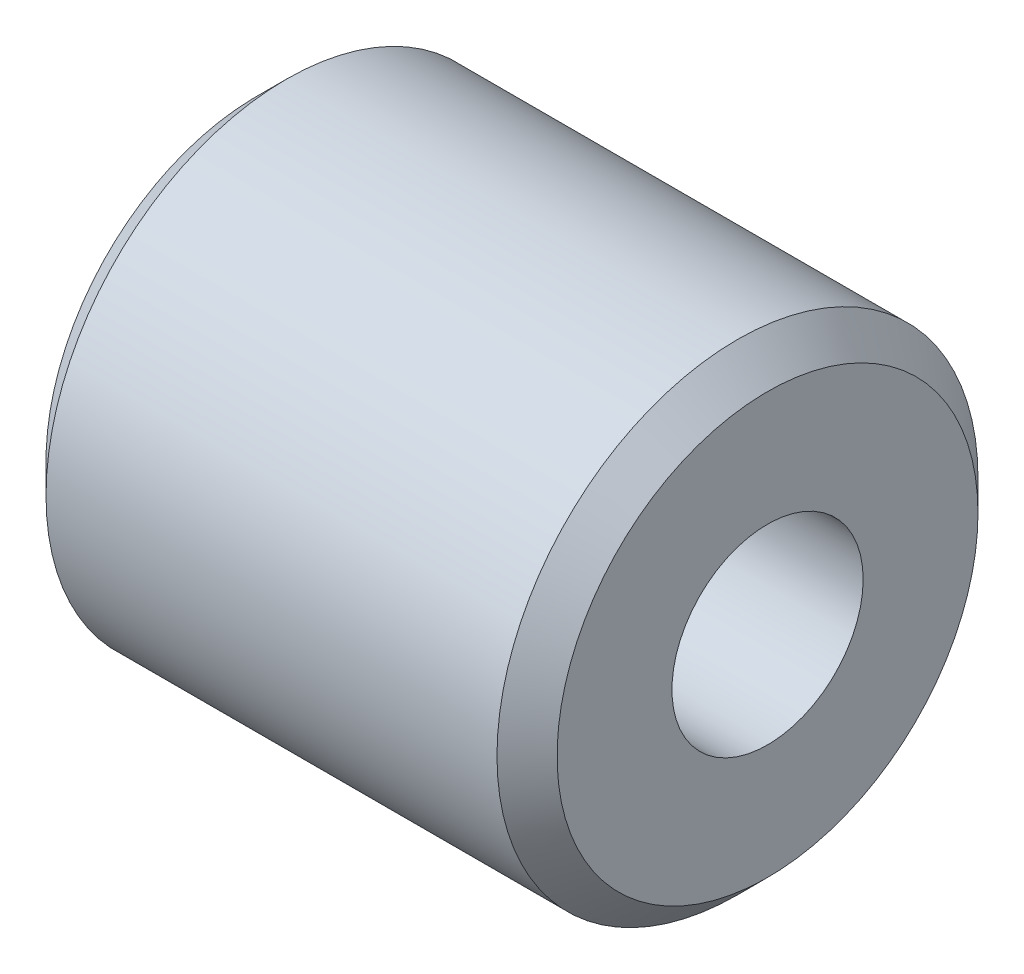
from build123d import *

# Parameters (mm, degrees)
SKETCH1_R           = 4
SKETCH1_R_2         = 1.59
BOSS_EXTRUDE1_DEPTH = 4.25
CHAMFER1_SIZE       = 0.5


with BuildPart() as part:
    # Sketch1 → Boss-Extrude1 (new body, symmetric)
    with BuildSketch(Plane(origin=(0, 0, 0), x_dir=(0, 0, -1), z_dir=(1, 0, 0))):
        Circle(SKETCH1_R)
        Circle(SKETCH1_R_2, mode=Mode.SUBTRACT)
    extrude(amount=BOSS_EXTRUDE1_DEPTH, both=True)

    # Chamfer1
    chamfer1_edges = [part.edges().sort_by_distance(p)[0] for p in [
        (-4.25, 0, 4),
        (4.25, 0, 4),
    ]]
    chamfer(chamfer1_edges, length=CHAMFER1_SIZE)


solid = part.part
